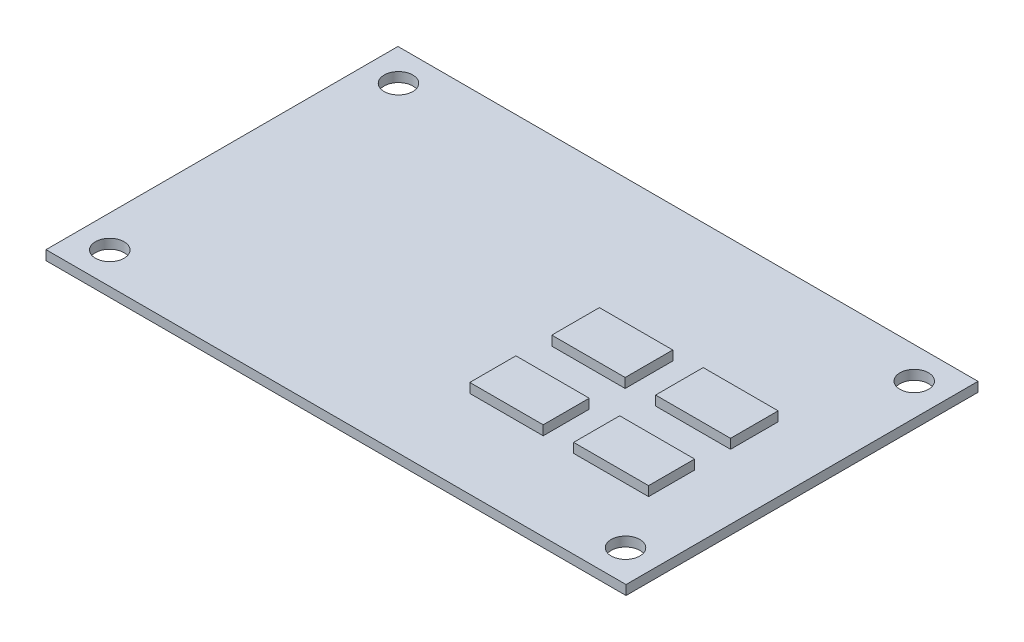
from build123d import *

# Parameters (mm, degrees)
SKETCH_2_W                = 60.73
SKETCH_2_H                = 36.85
EXTRUDE_1_DEPTH           = 1
HOLE_WIZARD_3_0_3_1_D     = 3
HOLE_WIZARD_3_0_3_1_DEPTH = 12.4
HOLE_WIZARD_3_0_3_1_TIP   = 0.901290929
SKETCH_6_W                = 7.681831357
SKETCH_6_H                = 4.985018222
SKETCH_6_W_2              = 7.845274578
SKETCH_6_H_2              = 4.821575001
EXTRUDE_2_DEPTH           = 1


with BuildPart() as part:
    # 草图2 → 凸台-拉伸1 (new body)
    with BuildSketch(Plane(origin=(0, 0, 0), x_dir=(1, 0, 0), z_dir=(0, 1, 0))):
        Rectangle(SKETCH_2_W, SKETCH_2_H)
    extrude(amount=EXTRUDE_1_DEPTH)

    # Ø3.0 (3) 直径孔1
    with Locations(Plane(origin=(0, 1, 0), x_dir=(1, 0, 0), z_dir=(0, 1, 0))):
        with Locations((-27, 15.115), (27, 15.115), (27, -15.115), (-27, -15.115)):
            Hole(HOLE_WIZARD_3_0_3_1_D / 2, depth=HOLE_WIZARD_3_0_3_1_DEPTH)
            with Locations((0, 0, -(HOLE_WIZARD_3_0_3_1_DEPTH + HOLE_WIZARD_3_0_3_1_TIP / 2))):  # 118° drill point
                Cone(0, HOLE_WIZARD_3_0_3_1_D / 2, HOLE_WIZARD_3_0_3_1_TIP, mode=Mode.SUBTRACT)

    # 草图6 → 凸台-拉伸2 (add)
    with BuildSketch(Plane(origin=(0, 1, 0), x_dir=(1, 0, 0), z_dir=(0, 1, 0))):
        with Locations((8.702195721, 1.796125826)):
            Rectangle(SKETCH_6_W, SKETCH_6_H)
        with Locations((19.652891485, 1.796125826)):
            Rectangle(SKETCH_6_W_2, SKETCH_6_H)
        with Locations((8.702195721, -6.866364854)):
            Rectangle(SKETCH_6_W, SKETCH_6_H_2)
        with Locations((19.652891485, -6.866364854)):
            Rectangle(SKETCH_6_W_2, SKETCH_6_H_2)
    extrude(amount=EXTRUDE_2_DEPTH)


solid = part.part
